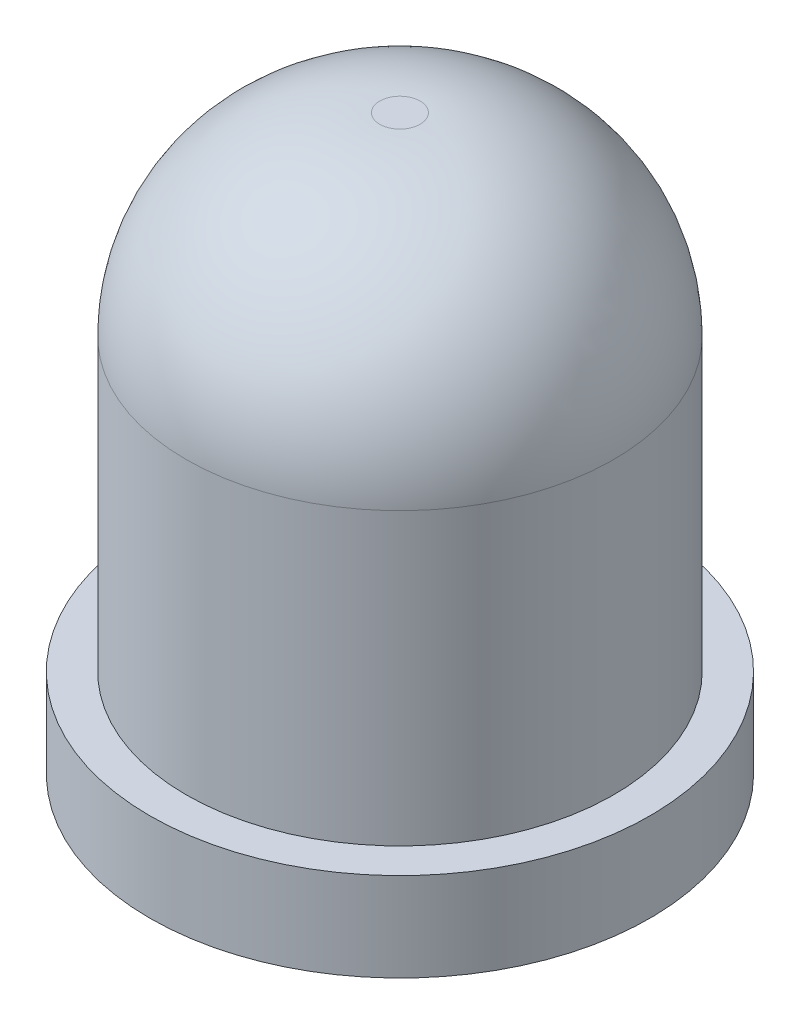
from build123d import *

# Parameters (mm, degrees)
ESQUISSE1_R      = 3.1
EXTRUSION1_DEPTH = 1.1
ESQUISSE2_R      = 2.65
EXTRUSION2_DEPTH = 6
CONG_1_R         = 2.4


with BuildPart() as part:
    # Esquisse1 → Extrusion1 (new body)
    with BuildSketch(Plane(origin=(0, 0, 0), x_dir=(1, 0, 0), z_dir=(0, 1, 0))):
        Circle(ESQUISSE1_R)
    extrude(amount=EXTRUSION1_DEPTH)

    # Esquisse2 → Extrusion2 (add)
    with BuildSketch(Plane(origin=(0, 1.1, 0), x_dir=(1, 0, 0), z_dir=(0, 1, 0))):
        Circle(ESQUISSE2_R)
    extrude(amount=EXTRUSION2_DEPTH)

    # Congé1
    cong_1_edges = [part.edges().sort_by_distance(p)[0] for p in [
        (-2.65, 7.1, 0),
    ]]
    fillet(cong_1_edges, radius=CONG_1_R)


solid = part.part
